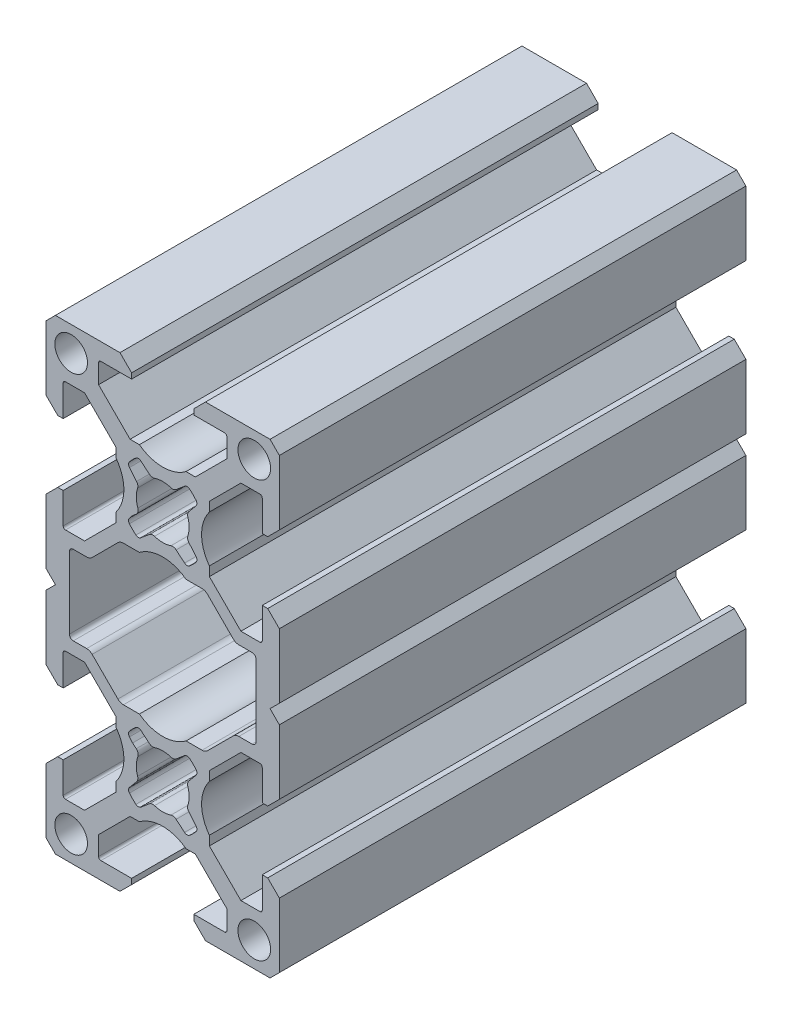
from build123d import *

# Parameters (mm, degrees)
EXTRUDE_1_DEPTH        = 60
CHAMFER_1_SIZE         = 1.2
CUT_EXTRUDE_1_DEPTH    = 61
HOLE_WIZARD_M41_D      = 4.2
SKETCH_6_W             = 1.8
SKETCH_6_H             = 10.2
EXTRUDE_2_DEPTH        = 60
FILLET_1_R             = 0.5
CUT_EXTRUDE_4943_DEPTH = 61
EXTRUDE_3_DEPTH        = 60


with BuildPart() as part:
    # Model → Бобышка-Вытянуть1 (new body)
    with BuildSketch(Plane.XY):
        with BuildLine():
            Line((-6, 19.19687748), (-6, 15.866025404))
            Line((-6, 15.866025404), (-5.5, 15))
            Line((-5.5, 15), (-6, 14.133974596))
            Line((-6, 14.133974596), (-6, 10.80312252))
            Line((-6, 10.80312252), (-10.05312252, 6.75))
            Line((-10.05312252, 6.75), (-12.5, 6.75))
            ThreePointArc((-12.5, 6.75), (-12.712132034, 6.837867966), (-12.8, 7.05))
            Line((-12.8, 7.05), (-12.8, 11))
            Line((-12.8, 11), (-14.5, 11))
            Line((-14.5, 11), (-14.5, 10.5))
            Line((-14.5, 10.5), (-15, 10.5))
            Line((-15, 10.5), (-15, -10.5))
            Line((-15, -10.5), (-14.5, -10.5))
            Line((-14.5, -10.5), (-14.5, -11))
            Line((-14.5, -11), (-12.8, -11))
            Line((-12.8, -11), (-12.8, -7.05))
            ThreePointArc((-12.8, -7.05), (-12.712132034, -6.837867966), (-12.5, -6.75))
            Line((-12.5, -6.75), (-10.05312252, -6.75))
            Line((-10.05312252, -6.75), (-6, -10.80312252))
            Line((-6, -10.80312252), (-6, -14.133974596))
            Line((-6, -14.133974596), (-5.5, -15))
            Line((-5.5, -15), (-6, -15.866025404))
            Line((-6, -15.866025404), (-6, -19.19687748))
            Line((-6, -19.19687748), (-10.05312252, -23.25))
            Line((-10.05312252, -23.25), (-12.5, -23.25))
            ThreePointArc((-12.5, -23.25), (-12.712132034, -23.162132034), (-12.8, -22.95))
            Line((-12.8, -22.95), (-12.8, -19))
            Line((-12.8, -19), (-14.5, -19))
            Line((-14.5, -19), (-14.5, -19.5))
            Line((-14.5, -19.5), (-15, -19.5))
            Line((-15, -19.5), (-15, -30))
            Line((-15, -30), (-4.5, -30))
            Line((-4.5, -30), (-4.5, -29.5))
            Line((-4.5, -29.5), (-4, -29.5))
            Line((-4, -29.5), (-4, -27.8))
            Line((-4, -27.8), (-7.95, -27.8))
            ThreePointArc((-7.95, -27.8), (-8.162132034, -27.712132034), (-8.25, -27.5))
            Line((-8.25, -27.5), (-8.25, -25.05312252))
            Line((-8.25, -25.05312252), (-4.19687748, -21))
            Line((-4.19687748, -21), (-0.866025404, -21))
            Line((-0.866025404, -21), (0, -20.5))
            Line((0, -20.5), (0.866025404, -21))
            Line((0.866025404, -21), (4.19687748, -21))
            Line((4.19687748, -21), (8.25, -25.05312252))
            Line((8.25, -25.05312252), (8.25, -27.5))
            ThreePointArc((8.25, -27.5), (8.162132034, -27.712132034), (7.95, -27.8))
            Line((7.95, -27.8), (4, -27.8))
            Line((4, -27.8), (4, -29.5))
            Line((4, -29.5), (4.5, -29.5))
            Line((4.5, -29.5), (4.5, -30))
            Line((4.5, -30), (15, -30))
            Line((15, -30), (15, -19.5))
            Line((15, -19.5), (14.5, -19.5))
            Line((14.5, -19.5), (14.5, -19))
            Line((14.5, -19), (12.8, -19))
            Line((12.8, -19), (12.8, -22.95))
            ThreePointArc((12.8, -22.95), (12.712132034, -23.162132034), (12.5, -23.25))
            Line((12.5, -23.25), (10.05312252, -23.25))
            Line((10.05312252, -23.25), (6, -19.19687748))
            Line((6, -19.19687748), (6, -15.866025404))
            Line((6, -15.866025404), (5.5, -15))
            Line((5.5, -15), (6, -14.133974596))
            Line((6, -14.133974596), (6, -10.80312252))
            Line((6, -10.80312252), (10.05312252, -6.75))
            Line((10.05312252, -6.75), (12.5, -6.75))
            ThreePointArc((12.5, -6.75), (12.712132034, -6.837867966), (12.8, -7.05))
            Line((12.8, -7.05), (12.8, -11))
            Line((12.8, -11), (14.5, -11))
            Line((14.5, -11), (14.5, -10.5))
            Line((14.5, -10.5), (15, -10.5))
            Line((15, -10.5), (15, 10.5))
            Line((15, 10.5), (14.5, 10.5))
            Line((14.5, 10.5), (14.5, 11))
            Line((14.5, 11), (12.8, 11))
            Line((12.8, 11), (12.8, 7.05))
            ThreePointArc((12.8, 7.05), (12.712132034, 6.837867966), (12.5, 6.75))
            Line((12.5, 6.75), (10.05312252, 6.75))
            Line((10.05312252, 6.75), (6, 10.80312252))
            Line((6, 10.80312252), (6, 14.133974596))
            Line((6, 14.133974596), (5.5, 15))
            Line((5.5, 15), (6, 15.866025404))
            Line((6, 15.866025404), (6, 19.19687748))
            Line((6, 19.19687748), (10.05312252, 23.25))
            Line((10.05312252, 23.25), (12.5, 23.25))
            ThreePointArc((12.5, 23.25), (12.712132034, 23.162132034), (12.8, 22.95))
            Line((12.8, 22.95), (12.8, 19))
            Line((12.8, 19), (14.5, 19))
            Line((14.5, 19), (14.5, 19.5))
            Line((14.5, 19.5), (15, 19.5))
            Line((15, 19.5), (15, 30))
            Line((15, 30), (4.5, 30))
            Line((4.5, 30), (4.5, 29.5))
            Line((4.5, 29.5), (4, 29.5))
            Line((4, 29.5), (4, 27.8))
            Line((4, 27.8), (7.95, 27.8))
            ThreePointArc((7.95, 27.8), (8.162132034, 27.712132034), (8.25, 27.5))
            Line((8.25, 27.5), (8.25, 25.05312252))
            Line((8.25, 25.05312252), (4.19687748, 21))
            Line((4.19687748, 21), (0.866025404, 21))
            Line((0.866025404, 21), (0, 20.5))
            Line((0, 20.5), (-0.866025404, 21))
            Line((-0.866025404, 21), (-4.19687748, 21))
            Line((-4.19687748, 21), (-8.25, 25.05312252))
            Line((-8.25, 25.05312252), (-8.25, 27.5))
            ThreePointArc((-8.25, 27.5), (-8.162132034, 27.712132034), (-7.95, 27.8))
            Line((-7.95, 27.8), (-4, 27.8))
            Line((-4, 27.8), (-4, 29.5))
            Line((-4, 29.5), (-4.5, 29.5))
            Line((-4.5, 29.5), (-4.5, 30))
            Line((-4.5, 30), (-15, 30))
            Line((-15, 30), (-15, 19.5))
            Line((-15, 19.5), (-14.5, 19.5))
            Line((-14.5, 19.5), (-14.5, 19))
            Line((-14.5, 19), (-12.8, 19))
            Line((-12.8, 19), (-12.8, 22.95))
            ThreePointArc((-12.8, 22.95), (-12.712132034, 23.162132034), (-12.5, 23.25))
            Line((-12.5, 23.25), (-10.05312252, 23.25))
            Line((-10.05312252, 23.25), (-6, 19.19687748))
        make_face()
        with BuildLine():
            Line((-1.855742139, 11.527081998), (-2.814492553, 10.722594832))
            ThreePointArc((-2.814492553, 10.722594832), (-3.130834465, 10.605642567), (-3.449474994, 10.716178764))
            ThreePointArc((-3.449474994, 10.716178764), (-3.889087433, 11.110912567), (-4.283821236, 11.550525006))
            ThreePointArc((-4.283821236, 11.550525006), (-4.394357433, 11.869165535), (-4.277405168, 12.185507447))
            Line((-4.277405168, 12.185507447), (-3.472918002, 13.144257861))
            ThreePointArc((-3.472918002, 13.144257861), (-3.362303548, 13.38613538), (-3.3913691, 13.650512922))
            ThreePointArc((-3.3913691, 13.650512922), (-3.649999965, 15), (-3.3913691, 16.349487078))
            ThreePointArc((-3.3913691, 16.349487078), (-3.362303548, 16.61386462), (-3.472918002, 16.855742139))
            Line((-3.472918002, 16.855742139), (-4.277405168, 17.814492553))
            ThreePointArc((-4.277405168, 17.814492553), (-4.394357433, 18.130834465), (-4.283821236, 18.449474994))
            ThreePointArc((-4.283821236, 18.449474994), (-3.889087433, 18.889087433), (-3.449474994, 19.283821236))
            ThreePointArc((-3.449474994, 19.283821236), (-3.130834465, 19.394357433), (-2.814492553, 19.277405168))
            Line((-2.814492553, 19.277405168), (-1.855742139, 18.472918002))
            ThreePointArc((-1.855742139, 18.472918002), (-1.61386462, 18.362303548), (-1.349487078, 18.3913691))
            ThreePointArc((-1.349487078, 18.3913691), (0, 18.649999965), (1.349487078, 18.3913691))
            ThreePointArc((1.349487078, 18.3913691), (1.61386462, 18.362303548), (1.855742139, 18.472918002))
            Line((1.855742139, 18.472918002), (2.814492553, 19.277405168))
            ThreePointArc((2.814492553, 19.277405168), (3.130834465, 19.394357433), (3.449474994, 19.283821236))
            ThreePointArc((3.449474994, 19.283821236), (3.889087433, 18.889087433), (4.283821236, 18.449474994))
            ThreePointArc((4.283821236, 18.449474994), (4.394357433, 18.130834465), (4.277405168, 17.814492553))
            Line((4.277405168, 17.814492553), (3.472918002, 16.855742139))
            ThreePointArc((3.472918002, 16.855742139), (3.362303548, 16.61386462), (3.3913691, 16.349487078))
            ThreePointArc((3.3913691, 16.349487078), (3.649999965, 15), (3.3913691, 13.650512922))
            ThreePointArc((3.3913691, 13.650512922), (3.362303548, 13.38613538), (3.472918002, 13.144257861))
            Line((3.472918002, 13.144257861), (4.277405168, 12.185507447))
            ThreePointArc((4.277405168, 12.185507447), (4.394357433, 11.869165535), (4.283821236, 11.550525006))
            ThreePointArc((4.283821236, 11.550525006), (3.889087433, 11.110912567), (3.449474994, 10.716178764))
            ThreePointArc((3.449474994, 10.716178764), (3.130834465, 10.605642567), (2.814492553, 10.722594832))
            Line((2.814492553, 10.722594832), (1.855742139, 11.527081998))
            ThreePointArc((1.855742139, 11.527081998), (1.61386462, 11.637696452), (1.349487078, 11.6086309))
            ThreePointArc((1.349487078, 11.6086309), (0, 11.350000035), (-1.349487078, 11.6086309))
            ThreePointArc((-1.349487078, 11.6086309), (-1.61386462, 11.637696452), (-1.855742139, 11.527081998))
        make_face(mode=Mode.SUBTRACT)
        with BuildLine():
            Line((9.076776924, 5.392893219), (5.762563361, 8.707106781))
            ThreePointArc((5.762563361, 8.707106781), (5.438140013, 8.923879533), (5.05545658, 9))
            Line((5.05545658, 9), (-5.05545658, 9))
            ThreePointArc((-5.05545658, 9), (-5.438140013, 8.923879533), (-5.762563361, 8.707106781))
            Line((-5.762563361, 8.707106781), (-9.076776924, 5.392893219))
            ThreePointArc((-9.076776924, 5.392893219), (-9.401200273, 5.176120467), (-9.783883705, 5.1))
            Line((-9.783883705, 5.1), (-12.35, 5.1))
            ThreePointArc((-12.35, 5.1), (-13.057106781, 4.807106781), (-13.35, 4.1))
            Line((-13.35, 4.1), (-13.35, -4.1))
            ThreePointArc((-13.35, -4.1), (-13.057106781, -4.807106781), (-12.35, -5.1))
            Line((-12.35, -5.1), (-9.783883705, -5.1))
            ThreePointArc((-9.783883705, -5.1), (-9.401200273, -5.176120467), (-9.076776924, -5.392893219))
            Line((-9.076776924, -5.392893219), (-5.762563361, -8.707106781))
            ThreePointArc((-5.762563361, -8.707106781), (-5.438140013, -8.923879533), (-5.05545658, -9))
            Line((-5.05545658, -9), (5.05545658, -9))
            ThreePointArc((5.05545658, -9), (5.438140013, -8.923879533), (5.762563361, -8.707106781))
            Line((5.762563361, -8.707106781), (9.076776924, -5.392893219))
            ThreePointArc((9.076776924, -5.392893219), (9.401200273, -5.176120467), (9.783883705, -5.1))
            Line((9.783883705, -5.1), (12.35, -5.1))
            ThreePointArc((12.35, -5.1), (13.057106781, -4.807106781), (13.35, -4.1))
            Line((13.35, -4.1), (13.35, 4.1))
            ThreePointArc((13.35, 4.1), (13.057106781, 4.807106781), (12.35, 5.1))
            Line((12.35, 5.1), (9.783883705, 5.1))
            ThreePointArc((9.783883705, 5.1), (9.401200273, 5.176120467), (9.076776924, 5.392893219))
        make_face(mode=Mode.SUBTRACT)
        with BuildLine():
            Line((-1.855742139, -18.472918002), (-2.814492553, -19.277405168))
            ThreePointArc((-2.814492553, -19.277405168), (-3.130834465, -19.394357433), (-3.449474994, -19.283821236))
            ThreePointArc((-3.449474994, -19.283821236), (-3.889087433, -18.889087433), (-4.283821236, -18.449474994))
            ThreePointArc((-4.283821236, -18.449474994), (-4.394357433, -18.130834465), (-4.277405168, -17.814492553))
            Line((-4.277405168, -17.814492553), (-3.472918002, -16.855742139))
            ThreePointArc((-3.472918002, -16.855742139), (-3.362303548, -16.61386462), (-3.3913691, -16.349487078))
            ThreePointArc((-3.3913691, -16.349487078), (-3.649999965, -15), (-3.3913691, -13.650512922))
            ThreePointArc((-3.3913691, -13.650512922), (-3.362303548, -13.38613538), (-3.472918002, -13.144257861))
            Line((-3.472918002, -13.144257861), (-4.277405168, -12.185507447))
            ThreePointArc((-4.277405168, -12.185507447), (-4.394357433, -11.869165535), (-4.283821236, -11.550525006))
            ThreePointArc((-4.283821236, -11.550525006), (-3.889087433, -11.110912567), (-3.449474994, -10.716178764))
            ThreePointArc((-3.449474994, -10.716178764), (-3.130834465, -10.605642567), (-2.814492553, -10.722594832))
            Line((-2.814492553, -10.722594832), (-1.855742139, -11.527081998))
            ThreePointArc((-1.855742139, -11.527081998), (-1.61386462, -11.637696452), (-1.349487078, -11.6086309))
            ThreePointArc((-1.349487078, -11.6086309), (0, -11.350000035), (1.349487078, -11.6086309))
            ThreePointArc((1.349487078, -11.6086309), (1.61386462, -11.637696452), (1.855742139, -11.527081998))
            Line((1.855742139, -11.527081998), (2.814492553, -10.722594832))
            ThreePointArc((2.814492553, -10.722594832), (3.130834465, -10.605642567), (3.449474994, -10.716178764))
            ThreePointArc((3.449474994, -10.716178764), (3.889087433, -11.110912567), (4.283821236, -11.550525006))
            ThreePointArc((4.283821236, -11.550525006), (4.394357433, -11.869165535), (4.277405168, -12.185507447))
            Line((4.277405168, -12.185507447), (3.472918002, -13.144257861))
            ThreePointArc((3.472918002, -13.144257861), (3.362303548, -13.38613538), (3.3913691, -13.650512922))
            ThreePointArc((3.3913691, -13.650512922), (3.649999965, -15), (3.3913691, -16.349487078))
            ThreePointArc((3.3913691, -16.349487078), (3.362303548, -16.61386462), (3.472918002, -16.855742139))
            Line((3.472918002, -16.855742139), (4.277405168, -17.814492553))
            ThreePointArc((4.277405168, -17.814492553), (4.394357433, -18.130834465), (4.283821236, -18.449474994))
            ThreePointArc((4.283821236, -18.449474994), (3.889087433, -18.889087433), (3.449474994, -19.283821236))
            ThreePointArc((3.449474994, -19.283821236), (3.130834465, -19.394357433), (2.814492553, -19.277405168))
            Line((2.814492553, -19.277405168), (1.855742139, -18.472918002))
            ThreePointArc((1.855742139, -18.472918002), (1.61386462, -18.362303548), (1.349487078, -18.3913691))
            ThreePointArc((1.349487078, -18.3913691), (0, -18.649999965), (-1.349487078, -18.3913691))
            ThreePointArc((-1.349487078, -18.3913691), (-1.61386462, -18.362303548), (-1.855742139, -18.472918002))
        make_face(mode=Mode.SUBTRACT)
    extrude(amount=EXTRUDE_1_DEPTH)

    # Фаска1
    chamfer_1_edges = [part.edges().sort_by_distance(p)[0] for p in [
        (15, 30, 30),
        (15, -30, 30),
        (-15, -30, 30),
        (-15, 30, 30),
    ]]
    chamfer(chamfer_1_edges, length=CHAMFER_1_SIZE)

    # Эскиз2 → Вырез-Вытянуть1 (cut, through all)
    with BuildSketch(Plane.XY.offset(60)):
        Polygon((-15, 1.2), (-13.8, 0), (-15, -1.2), align=None)
        Polygon((15, 1.2), (13.8, 0), (15, -1.2), align=None)
        Polygon((-4, 28.5), (-5.5, 30), (5.5, 30), (4, 28.5), align=None)
        Polygon((4, -28.5), (-4, -28.5), (-5.5, -30), (5.5, -30), align=None)
        Polygon((-15, 20.5), (-15, 9.5), (-13.5, 11), (-13.5, 19), align=None)
        Polygon((-15, -20.5), (-13.5, -19), (-13.5, -11), (-15, -9.5), align=None)
        Polygon((13.5, 19), (15, 20.5), (15, 9.5), (13.5, 11), align=None)
        Polygon((13.5, -11), (15, -9.5), (15, -20.5), (13.5, -19), align=None)
    extrude(amount=-CUT_EXTRUDE_1_DEPTH, mode=Mode.SUBTRACT)

    # Отверстие с зазором M41 (through all)
    with Locations(Plane.XY.offset(60)):
        with Locations((-11.775000095, 26.775000095), (11.775000095, 26.775000095), (11.775000095, -26.775000095), (-11.775000095, -26.775000095)):
            Hole(HOLE_WIZARD_M41_D / 2)

    # Эскиз6 → Бобышка-Вытянуть2 (add)
    with BuildSketch(Plane.XY.offset(60)):
        with Locations((-12.9, 0)):
            Rectangle(SKETCH_6_W, SKETCH_6_H)
        with Locations((12.9, 0)):
            Rectangle(SKETCH_6_W, SKETCH_6_H)
    extrude(amount=-EXTRUDE_2_DEPTH)

    # Скругление1
    fillet_1_edges = [part.edges().sort_by_distance(p)[0] for p in [
        (-12, 5.1, 30),
        (-12, -5.1, 30),
        (12, -5.1, 30),
        (12, 5.1, 30),
    ]]
    fillet(fillet_1_edges, radius=FILLET_1_R)

    # Эскиз7 → Cut-Extrude 4943 (cut, through all)
    with BuildSketch(Plane(origin=(0, 0, 0), x_dir=(-1, 0, 0), z_dir=(0, 0, -1))):
        with BuildLine():
            Line((4.664761516, -26.8), (-4.664761516, -26.8))
            ThreePointArc((-4.664761516, -26.8), (0, -20), (4.664761516, -26.8))
        make_face()
        with BuildLine():
            Line((11.8, -10.335238484), (11.8, -19.664761516))
            ThreePointArc((11.8, -19.664761516), (5, -15), (11.8, -10.335238484))
        make_face()
        with BuildLine():
            Line((-11.8, -10.335238484), (-11.8, -19.664761516))
            ThreePointArc((-11.8, -19.664761516), (-5, -15), (-11.8, -10.335238484))
        make_face()
        with BuildLine():
            Line((-11.8, 10.335238484), (-11.8, 19.664761516))
            ThreePointArc((-11.8, 19.664761516), (-5, 15), (-11.8, 10.335238484))
        make_face()
        with BuildLine():
            Line((11.8, 10.335238484), (11.8, 19.664761516))
            ThreePointArc((11.8, 19.664761516), (5, 15), (11.8, 10.335238484))
        make_face()
        with BuildLine():
            Line((4.664761516, 26.8), (-4.664761516, 26.8))
            ThreePointArc((-4.664761516, 26.8), (0, 20), (4.664761516, 26.8))
        make_face()
        with BuildLine():
            Line((2.179449472, 0.5), (-2.179449472, 0.5))
            ThreePointArc((-2.179449472, 0.5), (0, 10), (2.179449472, 0.5))
        make_face()
        with BuildLine():
            Line((-2.179449472, -0.5), (2.179449472, -0.5))
            ThreePointArc((2.179449472, -0.5), (0, -10), (-2.179449472, -0.5))
        make_face()
    extrude(amount=-CUT_EXTRUDE_4943_DEPTH, mode=Mode.SUBTRACT)

    # Эскиз9 → Бобышка-Вытянуть3 (add)
    with BuildSketch(Plane.XY.offset(60)):
        with BuildLine():
            Line((2.335117346, -11.124838415), (1.722644917, -11.638763835))
            ThreePointArc((1.722644917, -11.638763835), (1.405755393, -11.789769634), (1.055404428, -11.767953977))
            ThreePointArc((1.055404428, -11.767953977), (0, -11.6), (-1.055404428, -11.767953977))
            ThreePointArc((-1.055404428, -11.767953977), (-1.405755393, -11.789769634), (-1.722644917, -11.638763835))
            Line((-1.722644917, -11.638763835), (-2.335117346, -11.124838415))
            Line((-2.335117346, -11.124838415), (2.335117346, -11.124838415))
        make_face()
        with BuildLine():
            Line((-3.875161585, -12.664882654), (-3.402722745, -13.061305933))
            ThreePointArc((-3.402722745, -13.061305933), (-3.176521765, -13.416379537), (-3.194900462, -13.836981928))
            ThreePointArc((-3.194900462, -13.836981928), (-3.399523478, -14.943077928), (-3.232046023, -16.055404428))
            ThreePointArc((-3.232046023, -16.055404428), (-3.210230366, -16.405755393), (-3.361236165, -16.722644917))
            Line((-3.361236165, -16.722644917), (-3.875161585, -17.335117346))
            Line((-3.875161585, -17.335117346), (-3.875161585, -12.664882654))
        make_face()
        with BuildLine():
            Line((-2.335117346, -18.875161585), (-1.722644917, -18.361236165))
            ThreePointArc((-1.722644917, -18.361236165), (-1.405755393, -18.210230366), (-1.055404428, -18.232046023))
            ThreePointArc((-1.055404428, -18.232046023), (0, -18.4), (1.055404428, -18.232046023))
            ThreePointArc((1.055404428, -18.232046023), (1.405755393, -18.210230366), (1.722644917, -18.361236165))
            Line((1.722644917, -18.361236165), (2.335117346, -18.875161585))
            Line((2.335117346, -18.875161585), (-2.335117346, -18.875161585))
        make_face()
        with BuildLine():
            Line((3.875161585, -17.335117346), (3.361236165, -16.722644917))
            ThreePointArc((3.361236165, -16.722644917), (3.210230366, -16.405755393), (3.232046023, -16.055404428))
            ThreePointArc((3.232046023, -16.055404428), (3.4, -15), (3.232046023, -13.944595572))
            ThreePointArc((3.232046023, -13.944595572), (3.210230366, -13.594244607), (3.361236165, -13.277355083))
            Line((3.361236165, -13.277355083), (3.875161585, -12.664882654))
            Line((3.875161585, -12.664882654), (3.875161585, -17.335117346))
        make_face()
        with BuildLine():
            Line((2.335117346, 11.124838415), (-2.335117346, 11.124838415))
            Line((-2.335117346, 11.124838415), (-1.722644917, 11.638763835))
            ThreePointArc((-1.722644917, 11.638763835), (-1.405755393, 11.789769634), (-1.055404428, 11.767953977))
            ThreePointArc((-1.055404428, 11.767953977), (0, 11.6), (1.055404428, 11.767953977))
            ThreePointArc((1.055404428, 11.767953977), (1.405755393, 11.789769634), (1.722644917, 11.638763835))
            Line((1.722644917, 11.638763835), (2.335117346, 11.124838415))
        make_face()
        with BuildLine():
            Line((3.875161585, 17.335117346), (3.875161585, 12.664882654))
            Line((3.875161585, 12.664882654), (3.361236165, 13.277355083))
            ThreePointArc((3.361236165, 13.277355083), (3.210230366, 13.594244607), (3.232046023, 13.944595572))
            ThreePointArc((3.232046023, 13.944595572), (3.4, 15), (3.232046023, 16.055404428))
            ThreePointArc((3.232046023, 16.055404428), (3.210230366, 16.405755393), (3.361236165, 16.722644917))
            Line((3.361236165, 16.722644917), (3.875161585, 17.335117346))
        make_face()
        with BuildLine():
            Line((-2.335117346, 18.875161585), (2.335117346, 18.875161585))
            Line((2.335117346, 18.875161585), (1.722644917, 18.361236165))
            ThreePointArc((1.722644917, 18.361236165), (1.405755393, 18.210230366), (1.055404428, 18.232046023))
            ThreePointArc((1.055404428, 18.232046023), (0, 18.4), (-1.055404428, 18.232046023))
            ThreePointArc((-1.055404428, 18.232046023), (-1.405755393, 18.210230366), (-1.722644917, 18.361236165))
            Line((-1.722644917, 18.361236165), (-2.335117346, 18.875161585))
        make_face()
        with BuildLine():
            Line((-3.875161585, 12.664882654), (-3.875161585, 17.335117346))
            Line((-3.875161585, 17.335117346), (-3.361236165, 16.722644917))
            ThreePointArc((-3.361236165, 16.722644917), (-3.210230366, 16.405755393), (-3.232046023, 16.055404428))
            ThreePointArc((-3.232046023, 16.055404428), (-3.399523478, 14.943077928), (-3.194900462, 13.836981928))
            ThreePointArc((-3.194900462, 13.836981928), (-3.176521765, 13.416379537), (-3.402722745, 13.061305933))
            Line((-3.402722745, 13.061305933), (-3.875161585, 12.664882654))
        make_face()
    extrude(amount=-EXTRUDE_3_DEPTH)


solid = part.part
